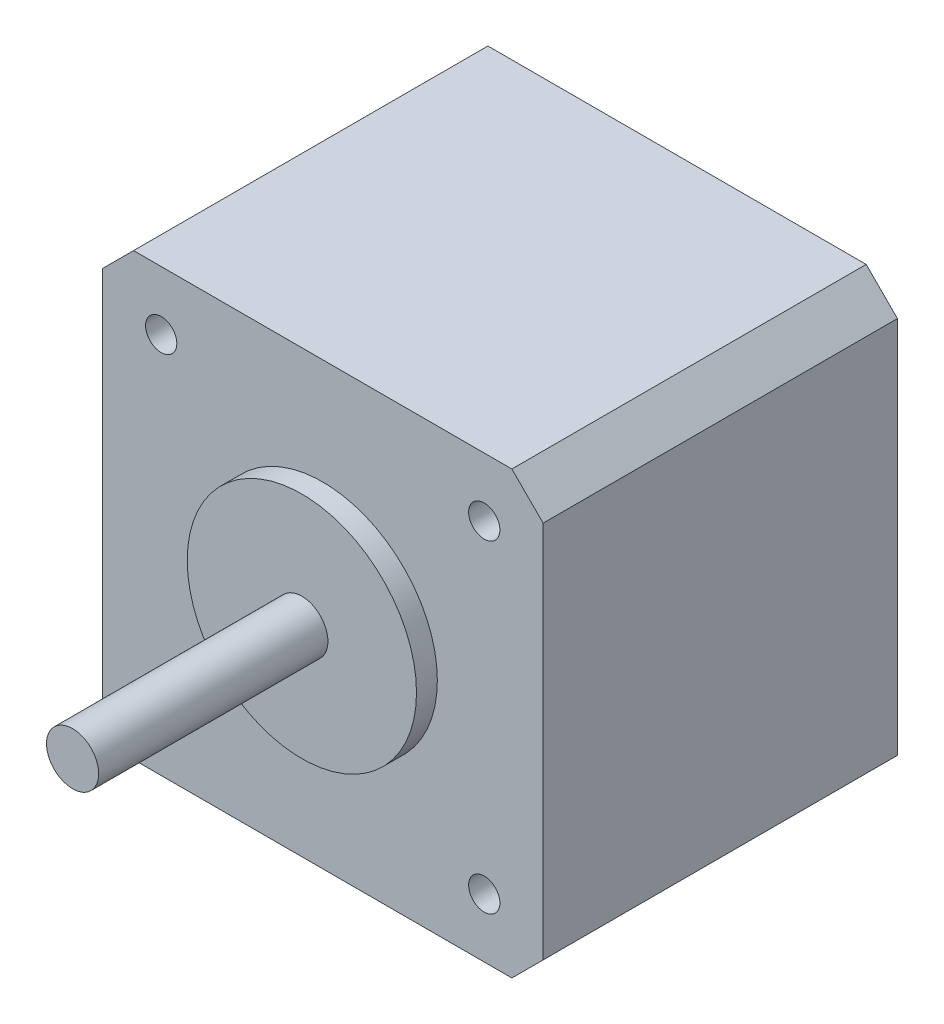
from build123d import *

# Parameters (mm, degrees)
SKETCH_1_W                = 42.3
SKETCH_1_H                = 42.3
EXTRUDE_1_DEPTH           = 34
HOLE_WIZARD_3_0_3_1_D     = 3
HOLE_WIZARD_3_0_3_1_DEPTH = 5
CHAMFER_1_SIZE            = 3


with BuildPart() as part:
    # 草图1 → 凸台-拉伸1 (new body)
    with BuildSketch(Plane.XY.offset(29)):
        with Locations((80, 0)):
            Rectangle(SKETCH_1_W, SKETCH_1_H)
    extrude(amount=-EXTRUDE_1_DEPTH)

    # 草图2 → 旋转1 (revolve)
    with BuildSketch(Plane.XZ):
        Polygon((82.5, 53), (80, 53), (80, 29), (91, 29), (91, 31), (82.5, 31), align=None)
    revolve(axis=Axis((80, 0, 53), (0, 0, -1)))

    # Ø3.0 (3) 直径孔1
    with Locations(Plane.XY.offset(29)):
        with Locations((95.5, 15.5), (95.5, -15.5), (64.5, -15.5), (64.5, 15.5)):
            Hole(HOLE_WIZARD_3_0_3_1_D / 2, depth=HOLE_WIZARD_3_0_3_1_DEPTH)

    # 倒角1
    chamfer_1_edges = [part.edges().sort_by_distance(p)[0] for p in [
        (58.85, 21.15, 12),
        (101.15, 21.15, 12),
        (101.15, -21.15, 12),
        (58.85, -21.15, 12),
    ]]
    chamfer(chamfer_1_edges, length=CHAMFER_1_SIZE)


solid = part.part
